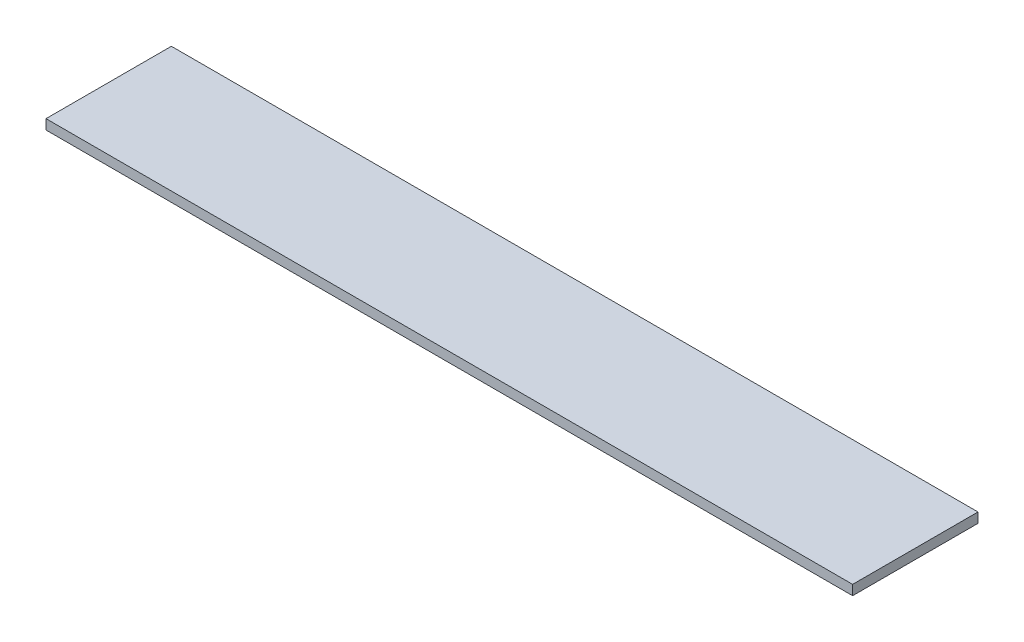
from build123d import *

# Parameters (mm, degrees)
SKETCH1_W           = 163.43
SKETCH1_H           = 25.4
BOSS_EXTRUDE1_DEPTH = 2


with BuildPart() as part:
    # Sketch1 → Boss-Extrude1 (new body)
    with BuildSketch(Plane(origin=(0, 0, 0), x_dir=(1, 0, 0), z_dir=(0, 1, 0))):
        Rectangle(SKETCH1_W, SKETCH1_H)
    extrude(amount=BOSS_EXTRUDE1_DEPTH)


solid = part.part
